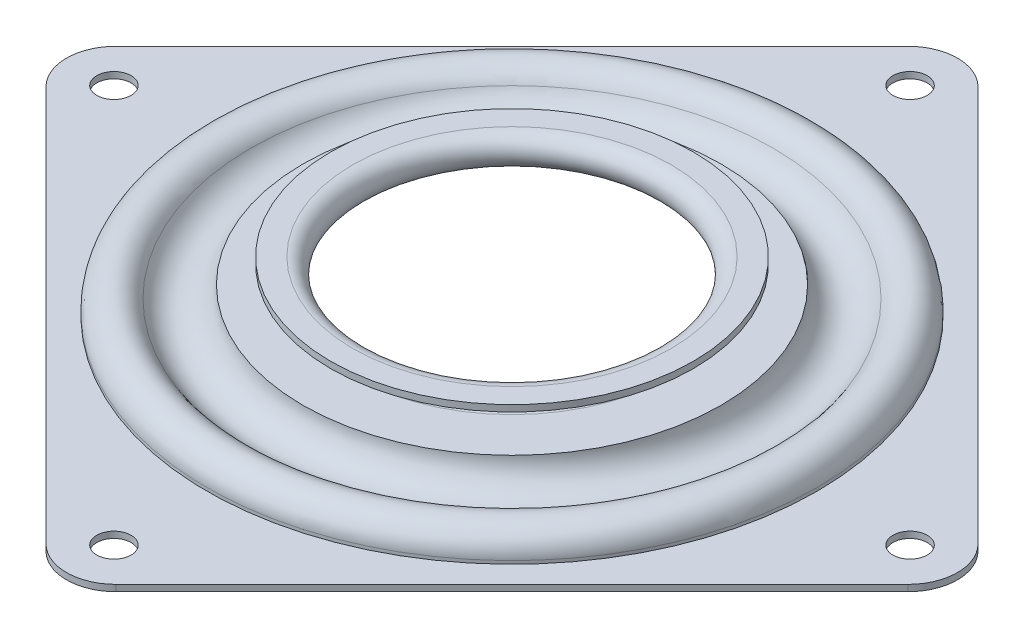
from build123d import *

# Parameters (mm, degrees)
BOSS_EXTRUDE2_START     = -0.736601
SKETCH5_R               = 34.517709056
BOSS_EXTRUDE2_DEPTH     = 0.736602
SKETCH7_R               = 1.984375
CUT_EXTRUDE2_DEPTH      = 3.67716
CUT_EXTRUDE2_DEPTH_BACK = 4.937001
FILLET2_R               = 5.715


with BuildPart() as part:
    # Sketch3 → Revolve-Thin1 (revolve)
    with BuildSketch(Plane.XY):
        with BuildLine():
            Line((38.1, -3.937), (34.517709056, -3.937))
            Line((34.517709056, -3.937), (34.517709056, -2.83464))
            ThreePointArc((34.517709056, -2.83464), (33.036848091, -0.927495427), (30.822306037, -1.88976))
            ThreePointArc((30.822306037, -1.88976), (26.821379497, -3.898798296), (23.527957004, -0.86614))
            Line((23.527957004, -0.86614), (18.40865, -0.86614))
            ThreePointArc((18.40865, -0.86614), (16.637, 0.90551), (18.40865, 2.67716))
            Line((18.40865, 2.67716), (20.968303502, 2.67716))
            Line((20.968303502, 2.67716), (20.968303502, 1.94056))
            Line((20.968303502, 1.94056), (18.40865, 1.94056))
            ThreePointArc((18.40865, 1.94056), (17.3736, 0.90551), (18.40865, -0.12954))
            Line((18.40865, -0.12954), (24.170722718, -0.12954))
            ThreePointArc((24.170722718, -0.12954), (26.638619821, -3.116060828), (30.176110069, -1.536192))
            ThreePointArc((30.176110069, -1.536192), (33.219319472, -0.213854232), (35.254309056, -2.83464))
            Line((35.254309056, -2.83464), (35.254309056, -3.2004))
            Line((35.254309056, -3.2004), (38.1, -3.2004))
            Line((38.1, -3.2004), (38.1, -3.937))
        make_face()
    revolve(axis=Axis((0, 3.937, 0), (0, -1, 0)))

    # Sketch5 → Boss-Extrude2 (add)
    with BuildSketch(Plane.XZ.offset(3.937).offset(BOSS_EXTRUDE2_START)):
        Polygon((-53.881536726, 0), (0, 53.881536726), (53.881536726, 0), (0, -53.881536726), align=None)
        Circle(SKETCH5_R, mode=Mode.SUBTRACT)
    extrude(amount=BOSS_EXTRUDE2_DEPTH)

    # Sketch7 → Cut-Extrude2 (cut, two sides)
    with BuildSketch(Plane(origin=(0, 0, 0), x_dir=(1, 0, 0), z_dir=(0, 1, 0))) as cut_extrude2_sk:
        with Locations((46.02381262, 0)):
            Circle(SKETCH7_R)
        with Locations((0, 46.02381262)):
            Circle(SKETCH7_R)
        with Locations((-46.02381262, 0)):
            Circle(SKETCH7_R)
        with Locations((0, -46.02381262)):
            Circle(SKETCH7_R)
    extrude(amount=CUT_EXTRUDE2_DEPTH, mode=Mode.SUBTRACT)
    extrude(cut_extrude2_sk.sketch, amount=-CUT_EXTRUDE2_DEPTH_BACK, mode=Mode.SUBTRACT)

    # Fillet2
    fillet2_edges = [part.edges().sort_by_distance(p)[0] for p in [
        (0, -3.5687, -53.881536726),
        (-53.881536726, -3.5687, 0),
        (0, -3.5687, 53.881536726),
        (53.881536726, -3.5687, 0),
    ]]
    fillet(fillet2_edges, radius=FILLET2_R)


solid = part.part
